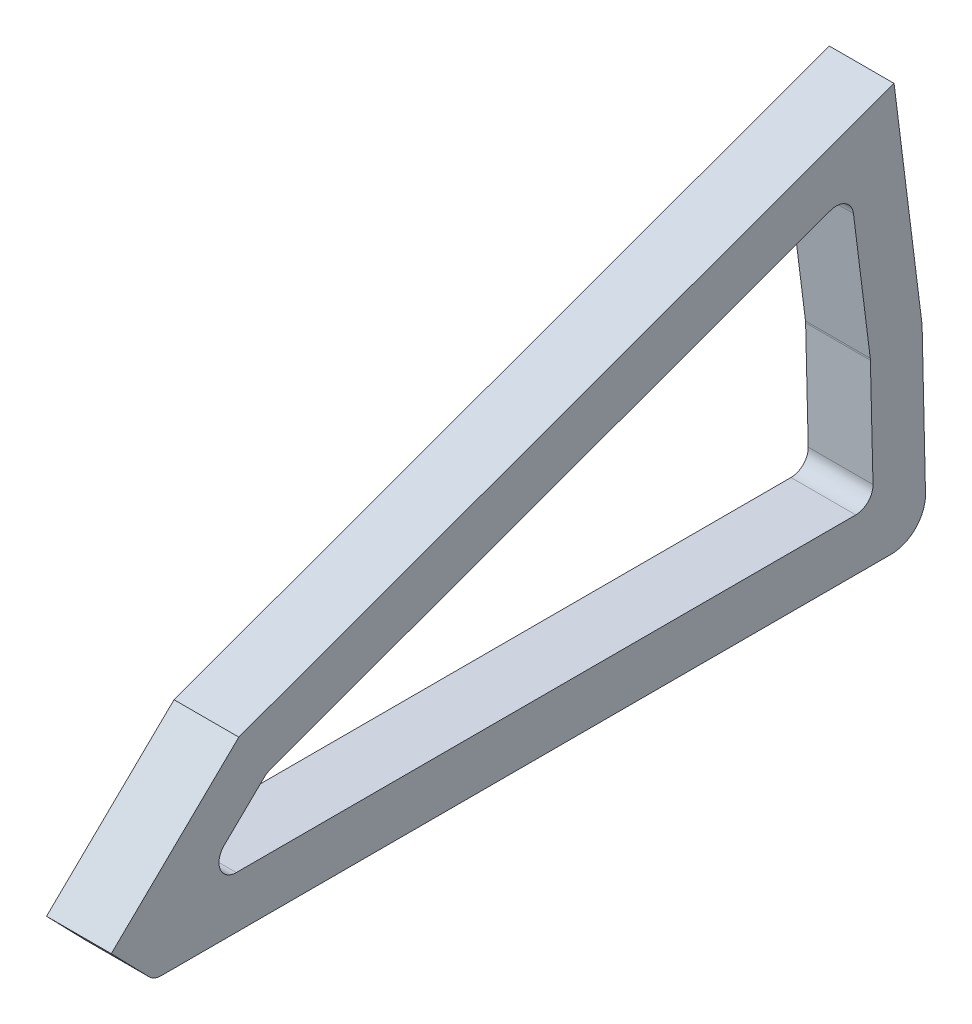
from build123d import *

# Parameters (mm, degrees)
BOSS_EXTRUDE1_DEPTH = 15


with BuildPart() as part:
    # Sketch1 → Boss-Extrude1 (new body)
    with BuildSketch(Plane(origin=(0, 0, 0), x_dir=(0, 0, -1), z_dir=(1, 0, 0))):
        with BuildLine():
            Line((-80.764356581, 24.012047683), (70.985255082, 79.244389389))
            Line((70.985255082, 79.244389389), (77.475739843, 27.555189639))
            Line((77.475739843, 27.555189639), (78.259876122, -6.675276303))
            ThreePointArc((78.259876122, -6.675276303), (75.98323725, -12.450192398), (70.261974321, -14.858488677))
            Line((70.261974321, -14.858488677), (-98.699643506, -14.858488677))
            ThreePointArc((-98.699643506, -14.858488677), (-100.257936009, -14.542470826), (-101.570004389, -13.644350914))
            Line((-101.570004389, -13.644350914), (-110.297725107, -4.651907634))
            Line((-110.297725107, -4.651907634), (-80.764356581, 24.012047683))
        make_face()
        with BuildLine():
            Line((-73.444540709, 13.906109511), (56.240883381, 61.107743698))
            ThreePointArc((56.240883381, 61.107743698), (59.694282591, 60.762394692), (61.577797623, 57.847329826))
            Line((61.577797623, 57.847329826), (65.468609196, 26.861518446))
            ThreePointArc((65.468609196, 26.861518446), (65.488687358, 26.660789803), (65.498619942, 26.45930416))
            Line((65.498619942, 26.45930416), (66.105012162, 1.237653648))
            ThreePointArc((66.105012162, 1.237653648), (64.968384485, -1.652717614), (62.106167747, -2.858488677))
            Line((62.106167747, -2.858488677), (-81.355445731, -2.858488677))
            ThreePointArc((-81.355445731, -2.858488677), (-85.062293687, -0.36157824), (-84.141307968, 4.011872206))
            Line((-84.141307968, 4.011872206), (-74.862322373, 13.017699911))
            ThreePointArc((-74.862322373, 13.017699911), (-74.200401783, 13.53686287), (-73.444540709, 13.906109511))
        make_face(mode=Mode.SUBTRACT)
    extrude(amount=BOSS_EXTRUDE1_DEPTH)


solid = part.part
